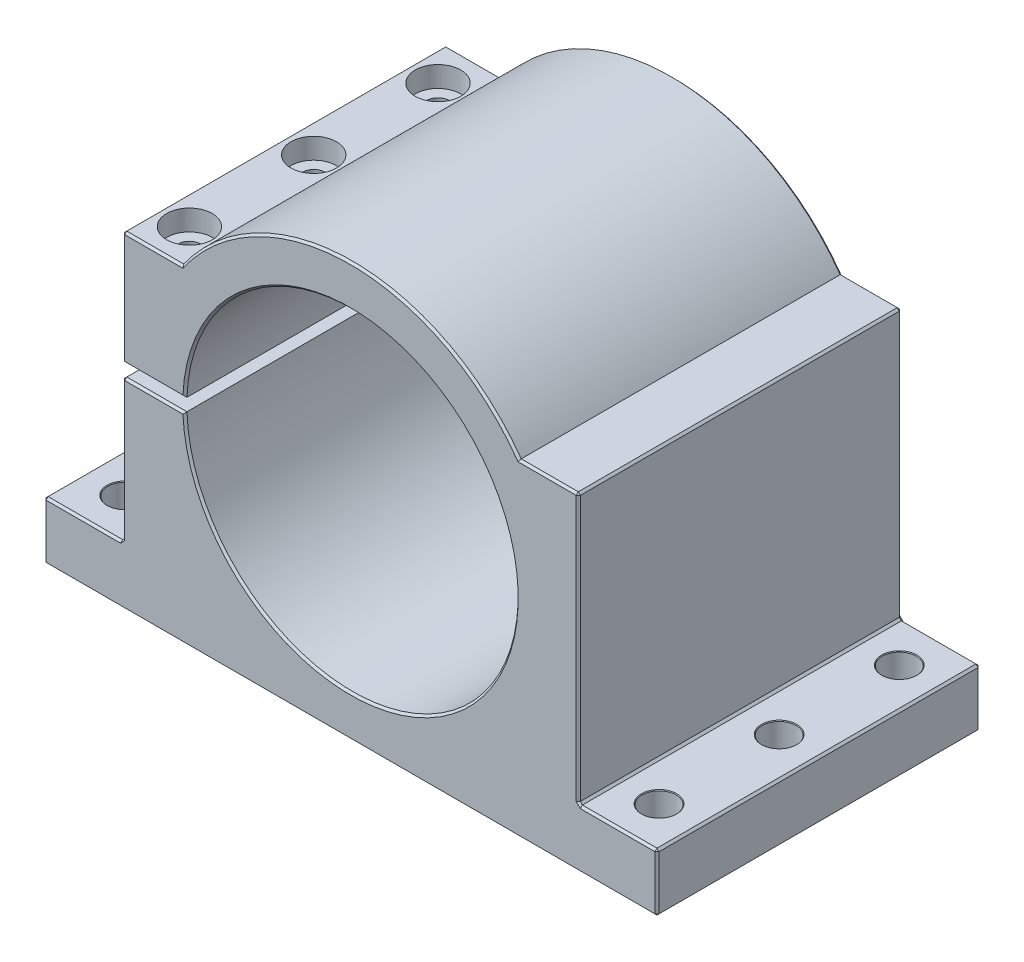
from build123d import *

# Parameters (mm, degrees)
EXTRUDE_1_DEPTH      = 39
SKETCH_2_R           = 5.5
CUT_EXTRUDE_1_DEPTH  = 5
SKETCH_3_R           = 2.75
CUT_EXTRUDE_2_DEPTH  = 25.5
SKETCH_4_R           = 2.1
CUT_EXTRUDE_3_DEPTH  = 30
HOLEWZD1_D           = 8.2
HOLEWZD1_DEPTH       = 16
HOLEWZD1_CSINK_D     = 8.5
HOLEWZD1_CSINK_ANGLE = 82
CHAMFER1_SIZE        = 0.5


with BuildPart() as part:
    # Эскиз1 → Бобышка-Вытянуть1 (new body, symmetric)
    with BuildSketch(Plane.XY):
        with BuildLine():
            Line((74, -50), (74, -36))
            Line((74, -36), (55, -36))
            Line((55, -36), (55, 29))
            Line((55, 29), (40.730823709, 29))
            ThreePointArc((40.730823709, 29), (0, 50), (-40.730823709, 29))
            Line((-40.730823709, 29), (-55, 29))
            Line((-55, 29), (-55, 1.5))
            Line((-55, 1.5), (-39.971865105, 1.5))
            ThreePointArc((-39.971865105, 1.5), (40, 0), (-39.971865105, -1.5))
            Line((-39.971865105, -1.5), (-55, -1.5))
            Line((-55, -1.5), (-55, -36))
            Line((-55, -36), (-74, -36))
            Line((-74, -36), (-74, -50))
            Line((-74, -50), (74, -50))
        make_face()
    extrude(amount=EXTRUDE_1_DEPTH, both=True)

    # Эскиз2 → Вырез-Вытянуть1 (cut)
    with BuildSketch(Plane(origin=(0, 29, 0), x_dir=(1, 0, 0), z_dir=(0, 1, 0))):
        with Locations((-47.865411854, 30)):
            Circle(SKETCH_2_R)
        with Locations((-47.865411854, 0)):
            Circle(SKETCH_2_R)
        with Locations((-47.865411854, -30)):
            Circle(SKETCH_2_R)
    extrude(amount=-CUT_EXTRUDE_1_DEPTH, mode=Mode.SUBTRACT)

    # Эскиз3 → Вырез-Вытянуть2 (cut)
    with BuildSketch(Plane(origin=(0, 24, 0), x_dir=(1, 0, 0), z_dir=(0, 1, 0))):
        with Locations((-47.865411854, 30)):
            Circle(SKETCH_3_R)
        with Locations((-47.865411854, 0)):
            Circle(SKETCH_3_R)
        with Locations((-47.865411854, -30)):
            Circle(SKETCH_3_R)
    extrude(amount=-CUT_EXTRUDE_2_DEPTH, mode=Mode.SUBTRACT)

    # Эскиз4 → Вырез-Вытянуть3 (cut)
    with BuildSketch(Plane(origin=(0, -1.5, 0), x_dir=(1, 0, 0), z_dir=(0, 1, 0))):
        with Locations((-47.865411854, 30)):
            Circle(SKETCH_4_R)
        with Locations((-47.865411854, 0)):
            Circle(SKETCH_4_R)
        with Locations((-47.865411854, -30)):
            Circle(SKETCH_4_R)
    extrude(amount=-CUT_EXTRUDE_3_DEPTH, mode=Mode.SUBTRACT)

    # HoleWzd1
    with Locations(Plane(origin=(0, -36, 0), x_dir=(1, 0, 0), z_dir=(0, 1, 0))):
        with Locations((-64.5, 29), (-64.5, 0), (-64.5, -29), (64.5, -29), (64.5, 0), (64.5, 29)):
            CounterSinkHole(HOLEWZD1_D / 2, HOLEWZD1_CSINK_D / 2, depth=HOLEWZD1_DEPTH, counter_sink_angle=HOLEWZD1_CSINK_ANGLE)

    # Chamfer1
    chamfer1_edges = [part.edges().sort_by_distance(p)[0] for p in [
        (-47.865411854, 29, 39),
        (55, -3.5, -39),
        (64.5, -36, -39),
        (74, -43, -39),
        (0, -50, -39),
        (-55, 15.25, 39),
        (-74, -43, -39),
        (-64.5, -36, -39),
        (-55, -18.75, -39),
        (-47.485932553, -1.5, -39),
        (40, 0, -39),
        (-47.485932553, 1.5, -39),
        (-55, 15.25, -39),
        (-47.485932553, 1.5, 39),
        (-47.865411854, 29, -39),
        (0, 50, -39),
        (47.865411854, 29, -39),
        (40, 0, 39),
        (55, 29, 0),
        (55, -36, 0),
        (74, -36, 0),
        (74, -50, 0),
        (-74, -50, 0),
        (-74, -36, 0),
        (-55, -36, 0),
        (-55, -1.5, 0),
        (-55, 1.5, 0),
        (-55, 29, 0),
        (-47.485932553, -1.5, 39),
        (-55, -18.75, 39),
        (-64.5, -36, 39),
        (47.865411854, 29, 39),
        (-74, -43, 39),
        (0, -50, 39),
        (74, -43, 39),
        (64.5, -36, 39),
        (55, -3.5, 39),
        (0, 50, 39),
    ]]
    chamfer(chamfer1_edges, length=CHAMFER1_SIZE)


solid = part.part
